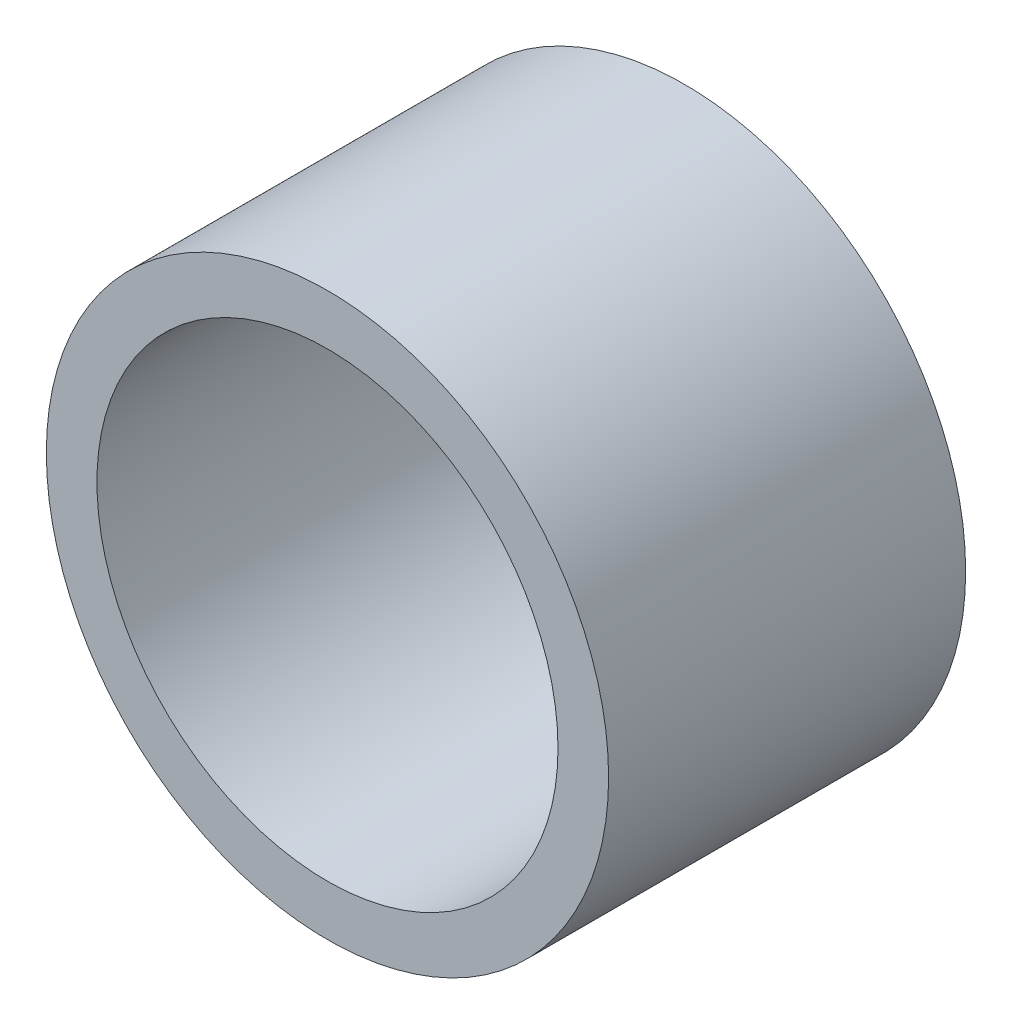
from build123d import *

# Parameters (mm, degrees)
SKETCH1_R           = 5
BOSS_EXTRUDE1_DEPTH = 6.35
SKETCH2_R           = 4.1
CUT_EXTRUDE1_DEPTH  = 7.35


with BuildPart() as part:
    # Sketch1 → Boss-Extrude1 (new body)
    with BuildSketch(Plane.XY):
        Circle(SKETCH1_R)
    extrude(amount=BOSS_EXTRUDE1_DEPTH)

    # Sketch2 → Cut-Extrude1 (cut, through all)
    with BuildSketch(Plane.XY.offset(6.35)):
        Circle(SKETCH2_R)
    extrude(amount=-CUT_EXTRUDE1_DEPTH, mode=Mode.SUBTRACT)


solid = part.part
